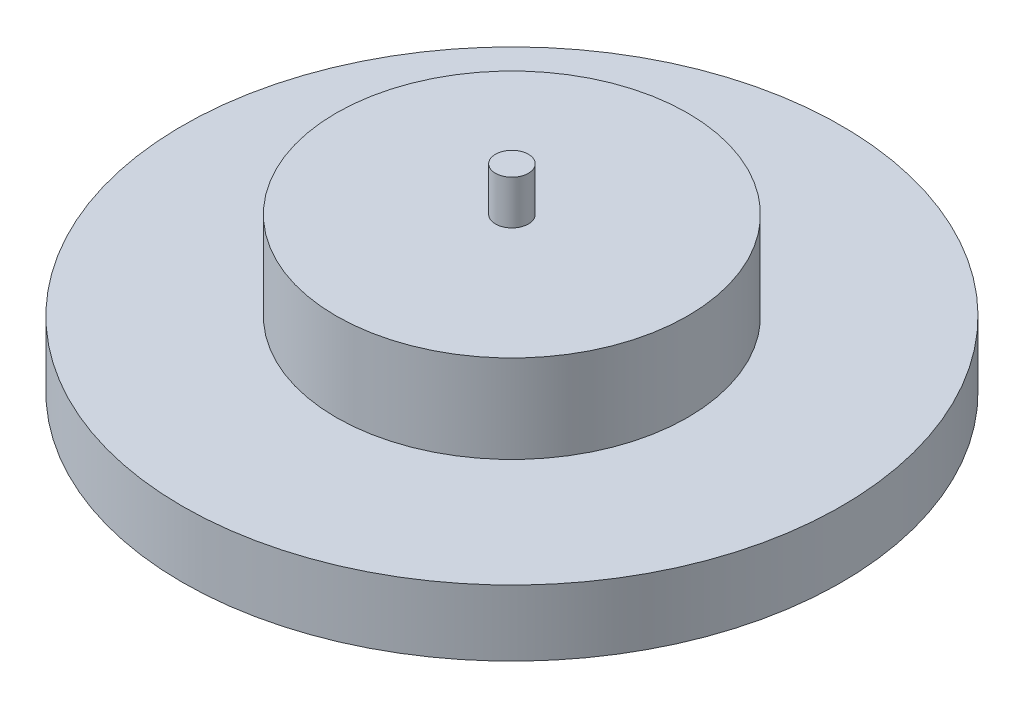
from build123d import *

# Parameters (mm, degrees)
SKETCH_1_R      = 15
EXTRUDE_1_DEPTH = 3
SKETCH_2_R      = 8
EXTRUDE_2_DEPTH = 4
SKETCH_3_R      = 0.75
EXTRUDE_3_DEPTH = 2


with BuildPart() as part:
    # 草图1 → 凸台-拉伸1 (new body)
    with BuildSketch(Plane(origin=(0, 0, 0), x_dir=(1, 0, 0), z_dir=(0, 1, 0))):
        Circle(SKETCH_1_R)
    extrude(amount=EXTRUDE_1_DEPTH)

    # 草图2 → 凸台-拉伸2 (add)
    with BuildSketch(Plane(origin=(0, 3, 0), x_dir=(1, 0, 0), z_dir=(0, 1, 0))):
        Circle(SKETCH_2_R)
    extrude(amount=EXTRUDE_2_DEPTH)

    # 草图3 → 凸台-拉伸3 (add)
    with BuildSketch(Plane(origin=(0, 7, 0), x_dir=(1, 0, 0), z_dir=(0, 1, 0))):
        Circle(SKETCH_3_R)
    extrude(amount=EXTRUDE_3_DEPTH)


solid = part.part
